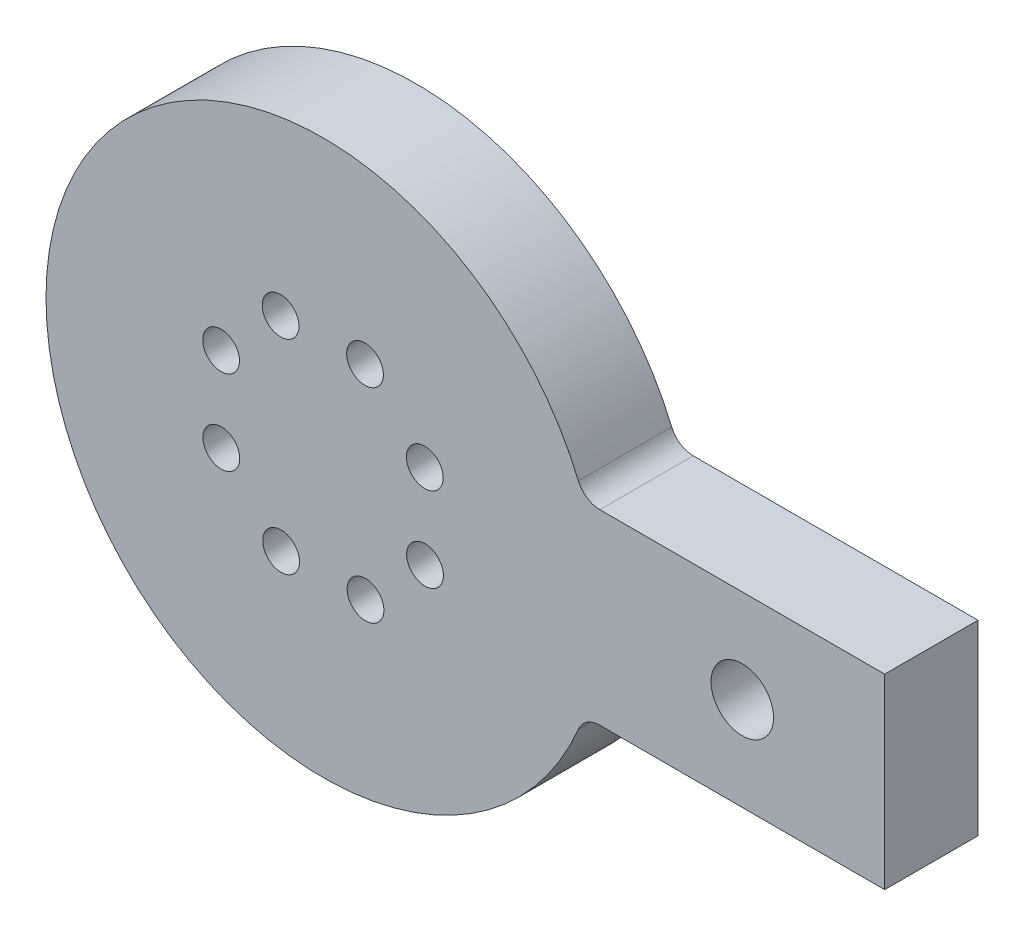
from build123d import *

# Parameters (mm, degrees)
SKETCH1_R                        = 2.5
BOSS_EXTRUDE1_DEPTH              = 12.7
FILLET1_R                        = 3.175
TAP_DRILL_FOR_M10X1_5_TAP1_D     = 8.5
TAP_DRILL_FOR_M10X1_5_TAP1_DEPTH = 20
TAP_DRILL_FOR_M10X1_5_TAP1_TIP   = 2.553657631


with BuildPart() as part:
    # Sketch1 → Boss-Extrude1 (new body)
    with BuildSketch(Plane.XY):
        with BuildLine():
            ThreePointArc((25, 0), (24.117920391, -6.582242475), (21.53392672, -12.7))
            Line((21.53392672, -12.7), (35.496478699, -12.7))
            ThreePointArc((35.496478699, -12.7), (37.145034977, -6.444872111), (37.7, 0))
            ThreePointArc((37.7, 0), (37.145034977, 6.444872111), (35.496478699, 12.7))
            Line((35.496478699, 12.7), (21.53392672, 12.7))
            ThreePointArc((21.53392672, 12.7), (24.117920391, 6.582242475), (25, 0))
        make_face()
        with BuildLine():
            Line((35.496478699, -12.7), (21.53392672, -12.7))
            ThreePointArc((21.53392672, -12.7), (-25, 0), (21.53392672, 12.7))
            Line((21.53392672, 12.7), (35.496478699, 12.7))
            ThreePointArc((35.496478699, 12.7), (-37.7, 0), (35.496478699, -12.7))
        make_face()
        with BuildLine():
            ThreePointArc((37.7, 0), (37.145034977, -6.444872111), (35.496478699, -12.7))
            Line((35.496478699, -12.7), (76.417300015, -12.7))
            Line((76.417300015, -12.7), (76.417300015, 12.7))
            Line((76.417300015, 12.7), (35.496478699, 12.7))
            ThreePointArc((35.496478699, 12.7), (37.145034977, 6.444872111), (37.7, 0))
        make_face()
        with BuildLine():
            Line((-1.017300015, 12.7), (-1.017300015, -12.7))
            Line((-1.017300015, -12.7), (3.552069768, -12.7))
            ThreePointArc((3.552069768, -12.7), (5.775120383, -11.34369837), (7.998170999, -12.7))
            Line((7.998170999, -12.7), (21.53392672, -12.7))
            ThreePointArc((21.53392672, -12.7), (24.117920391, -6.582242475), (25, 0))
            ThreePointArc((25, 0), (24.117920391, 6.582242475), (21.53392672, 12.7))
            Line((21.53392672, 12.7), (7.913288635, 12.7))
            ThreePointArc((7.913288635, 12.7), (5.705346209, 11.372599779), (3.497403783, 12.7))
            Line((3.497403783, 12.7), (-1.017300015, 12.7))
        make_face()
        with Locations((13.872599779, -5.705346209)):
            Circle(SKETCH1_R, mode=Mode.SUBTRACT)
        with Locations((13.84369837, 5.775120383)):
            Circle(SKETCH1_R, mode=Mode.SUBTRACT)
        with BuildLine():
            Line((3.552069768, -12.7), (-1.017300015, -12.7))
            Line((-1.017300015, -12.7), (-1.017300015, 12.7))
            Line((-1.017300015, 12.7), (3.497403783, 12.7))
            ThreePointArc((3.497403783, 12.7), (5.101134353, 16.29848684), (8.205346209, 13.872599779))
            ThreePointArc((8.205346209, 13.872599779), (8.13123327, 13.268387923), (7.913288635, 12.7))
            Line((7.913288635, 12.7), (21.53392672, 12.7))
            ThreePointArc((21.53392672, 12.7), (-25, 0), (21.53392672, -12.7))
            Line((21.53392672, -12.7), (7.998170999, -12.7))
            ThreePointArc((7.998170999, -12.7), (8.204896766, -13.255322019), (8.275120383, -13.84369837))
            ThreePointArc((8.275120383, -13.84369837), (5.186744032, -16.273474753), (3.552069768, -12.7))
        make_face()
        with Locations((-13.84369837, -5.775120383)):
            Circle(SKETCH1_R, mode=Mode.SUBTRACT)
        with Locations((-5.705346209, -13.872599779)):
            Circle(SKETCH1_R, mode=Mode.SUBTRACT)
        with Locations((-13.872599779, 5.705346209)):
            Circle(SKETCH1_R, mode=Mode.SUBTRACT)
        with Locations((-5.775120383, 13.84369837)):
            Circle(SKETCH1_R, mode=Mode.SUBTRACT)
    extrude(amount=BOSS_EXTRUDE1_DEPTH)

    # Fillet1
    fillet1_edges = [part.edges().sort_by_distance(p)[0] for p in [
        (35.496478699, 12.7, 6.35),
        (35.496478699, -12.7, 6.35),
    ]]
    fillet(fillet1_edges, radius=FILLET1_R)

    # Tap Drill for M10x1.5 Tap1
    with Locations(Plane.XY.offset(12.7)):
        with Locations((57.041798974, 0)):
            Hole(TAP_DRILL_FOR_M10X1_5_TAP1_D / 2, depth=TAP_DRILL_FOR_M10X1_5_TAP1_DEPTH)
            with Locations((0, 0, -(TAP_DRILL_FOR_M10X1_5_TAP1_DEPTH + TAP_DRILL_FOR_M10X1_5_TAP1_TIP / 2))):  # 118° drill point
                Cone(0, TAP_DRILL_FOR_M10X1_5_TAP1_D / 2, TAP_DRILL_FOR_M10X1_5_TAP1_TIP, mode=Mode.SUBTRACT)


solid = part.part
